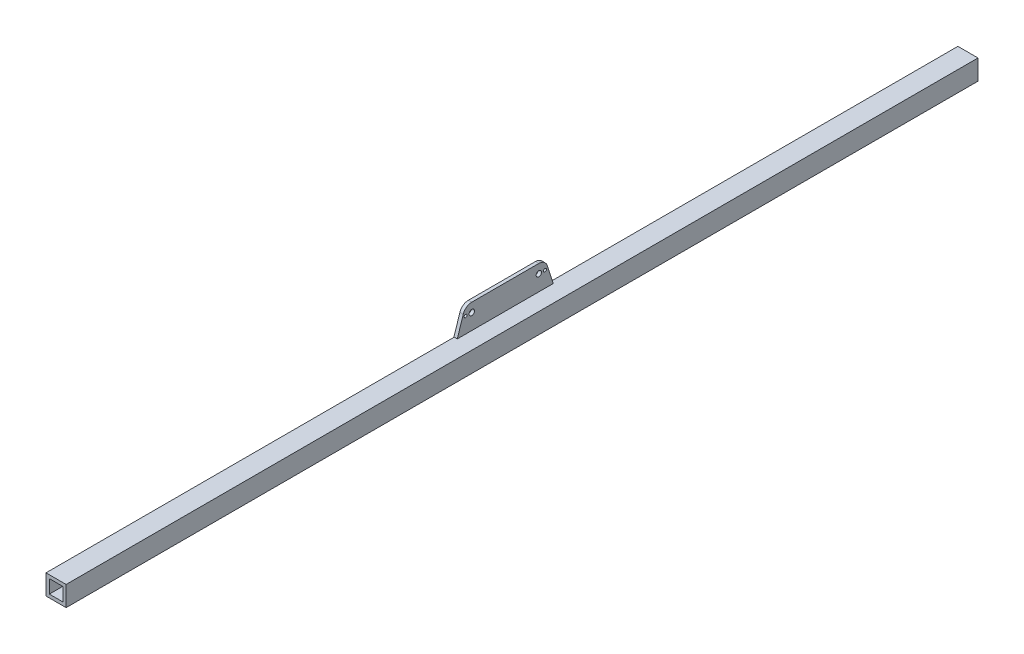
from build123d import *

# Parameters (mm, degrees)
SKETCH1_W           = 19.05
SKETCH1_H           = 19.05
BOSS_EXTRUDE1_DEPTH = 863.6
CUT_EXTRUDE1_REACH  = 865.6
SKETCH2_W           = 12.7
SKETCH2_H           = 12.7
BOSS_EXTRUDE2_DEPTH = 3.175
SKETCH5_R           = 1.367056659
SKETCH5_R_2         = 2.557242264
SKETCH5_R_3         = 2.557551724
CUT_EXTRUDE2_DEPTH  = 3.175


with BuildPart() as part:
    # Sketch1 → Boss-Extrude1 (new body)
    with BuildSketch(Plane.XY):
        Rectangle(SKETCH1_W, SKETCH1_H)
    extrude(amount=-BOSS_EXTRUDE1_DEPTH)

    # Sketch2 → Cut-Extrude1 (cut, up to next)
    with BuildSketch(Plane.XY, mode=Mode.PRIVATE) as cut_extrude1_sk1:
        Rectangle(SKETCH2_W, SKETCH2_H)
    cut_extrude1_tool1 = extrude(cut_extrude1_sk1.sketch, amount=-CUT_EXTRUDE1_REACH, mode=Mode.PRIVATE) & part.part
    add(cut_extrude1_tool1.solids().sort_by_distance((0, 0, 0))[0], mode=Mode.SUBTRACT)


with BuildPart() as body_2:
    # Sketch3 → Boss-Extrude2 (new body)
    with BuildSketch(Plane.ZY.offset(9.525)):
        with BuildLine():
            Line((-400.05, 33.085539952), (-463.55, 33.085539952))
            add(Edge.make_bspline(
                [(-463.55, 33.085539952), (-463.646128521, 33.084595214), (-463.838385563, 33.082705738), (-464.126436973, 33.067428476), (-464.413820455, 33.043060852), (-464.700203047, 33.0087375), (-465.080269374, 32.950070985), (-465.457006855, 32.872028355), (-465.829116116, 32.774907208), (-466.231406358, 32.655132939), (-466.750263355, 32.467816052), (-467.372247923, 32.185361594), (-467.969578868, 31.853591769), (-468.537542338, 31.472566802), (-469.07395459, 31.049637904), (-469.740655492, 30.429656969), (-470.460548641, 29.57349801), (-470.95574341, 28.755452697), (-471.240535683, 28.173623773), (-471.382062435, 27.852802616), (-471.514169404, 27.509958219), (-471.582805089, 27.304132504), (-471.608786902, 27.226217855)],
                knots=[0, 0, 0, 0, 0.027082523, 0.054165045, 0.081247568, 0.108330091, 0.135412613, 0.189577659, 0.216660181, 0.243742704, 0.307821112, 0.371897307, 0.436011013, 0.500107189, 0.564389201, 0.62826361, 0.756365308, 0.878115553, 0.896531504, 0.938874057, 0.976860975, 1, 1, 1, 1], degree=3))
            Line((-471.608786902, 27.226217855), (-477.264861875, 9.777442657))
            Line((-477.264861875, 9.777442657), (-386.335138125, 9.777442657))
            Line((-386.335138125, 9.777442657), (-391.991213098, 27.226217855))
            add(Edge.make_bspline(
                [(-391.991213098, 27.226217855), (-392.021753734, 27.317370774), (-392.082835007, 27.499676612), (-392.186190582, 27.768980594), (-392.297987591, 28.034846115), (-392.41894656, 28.296689598), (-392.591950531, 28.64014527), (-392.782359956, 28.974459542), (-392.989491068, 29.298488124), (-393.227477956, 29.644241729), (-393.565660364, 30.080054599), (-394.026144491, 30.584633328), (-394.525938749, 31.050553035), (-395.063532301, 31.473348142), (-395.631258779, 31.853208118), (-396.426610529, 32.296245416), (-397.463033709, 32.717055707), (-398.393913099, 32.935869659), (-399.035207635, 33.027372958), (-399.384036197, 33.063075641), (-399.75091015, 33.083026532), (-399.967870418, 33.084849771), (-400.05, 33.085539952)],
                knots=[0, 0, 0, 0, 0.027082523, 0.054165045, 0.081247568, 0.108330091, 0.135412613, 0.189577659, 0.216660181, 0.243742704, 0.307821112, 0.371897307, 0.436011013, 0.500107189, 0.564389201, 0.62826361, 0.756365308, 0.878115553, 0.896531502, 0.938874057, 0.976860979, 1, 1, 1, 1], degree=3))
        make_face()
    extrude(amount=-BOSS_EXTRUDE2_DEPTH)

    # Sketch5 → Cut-Extrude2 (cut)
    with BuildSketch(Plane.ZY.offset(9.525)):
        with Locations((-394.208, 24.613936913)):
            Circle(SKETCH5_R)
        with Locations((-469.392, 24.613936913)):
            Circle(SKETCH5_R)
        with Locations((-400.05, 24.613936913)):
            Circle(SKETCH5_R_2)
        with Locations((-463.55, 24.613936913)):
            Circle(SKETCH5_R_3)
    extrude(amount=-CUT_EXTRUDE2_DEPTH, mode=Mode.SUBTRACT)


solid = Compound([part.part, body_2.part])
